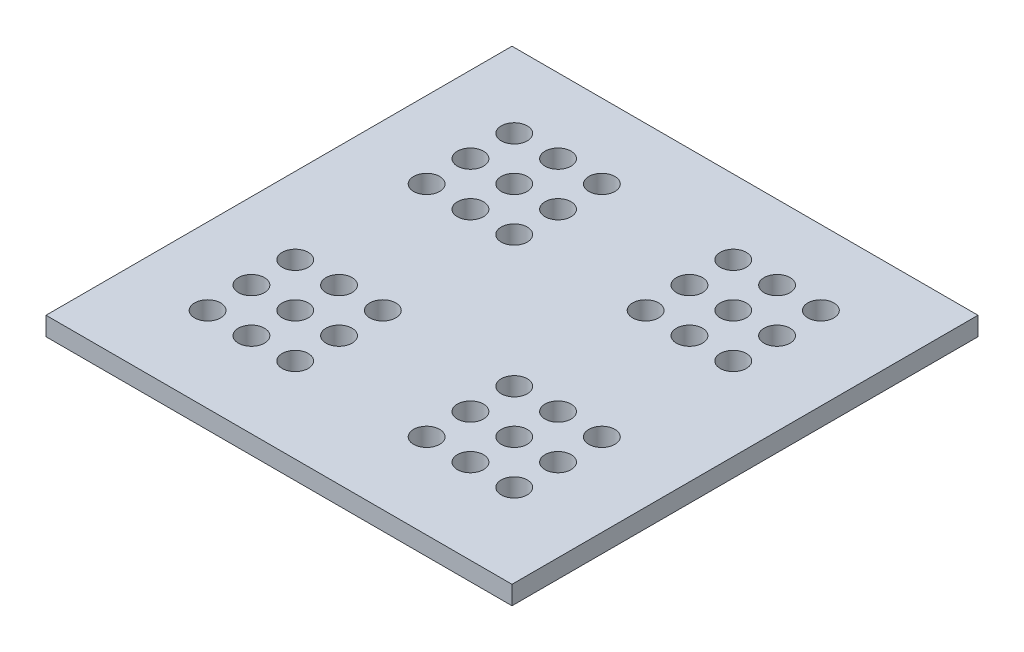
from build123d import *

# Parameters (mm, degrees)
SKETCH1_W           = 25
SKETCH1_H           = 25
SKETCH1_R           = 0.7
BOSS_EXTRUDE2_DEPTH = 1


with BuildPart() as part:
    # Sketch1 → Boss-Extrude2 (new body)
    with BuildSketch(Plane(origin=(0, 0, 0), x_dir=(1, 0, 0), z_dir=(0, 1, 0))):
        Rectangle(SKETCH1_W, SKETCH1_H)
        with Locations((-8.39, 8.51)):
            Circle(SKETCH1_R, mode=Mode.SUBTRACT)
        with Locations((-6.04, 8.51)):
            Circle(SKETCH1_R, mode=Mode.SUBTRACT)
        with Locations((-3.69, 8.51)):
            Circle(SKETCH1_R, mode=Mode.SUBTRACT)
        with Locations((3.36, 8.51)):
            Circle(SKETCH1_R, mode=Mode.SUBTRACT)
        with Locations((5.71, 8.51)):
            Circle(SKETCH1_R, mode=Mode.SUBTRACT)
        with Locations((8.06, 8.51)):
            Circle(SKETCH1_R, mode=Mode.SUBTRACT)
        with Locations((-6.04, 6.16)):
            Circle(SKETCH1_R, mode=Mode.SUBTRACT)
        with Locations((-3.69, 6.16)):
            Circle(SKETCH1_R, mode=Mode.SUBTRACT)
        with Locations((3.36, 6.16)):
            Circle(SKETCH1_R, mode=Mode.SUBTRACT)
        with Locations((5.71, 6.16)):
            Circle(SKETCH1_R, mode=Mode.SUBTRACT)
        with Locations((8.06, 6.16)):
            Circle(SKETCH1_R, mode=Mode.SUBTRACT)
        with Locations((-6.04, 3.81)):
            Circle(SKETCH1_R, mode=Mode.SUBTRACT)
        with Locations((-3.69, 3.81)):
            Circle(SKETCH1_R, mode=Mode.SUBTRACT)
        with Locations((3.36, 3.81)):
            Circle(SKETCH1_R, mode=Mode.SUBTRACT)
        with Locations((5.71, 3.81)):
            Circle(SKETCH1_R, mode=Mode.SUBTRACT)
        with Locations((8.06, 3.81)):
            Circle(SKETCH1_R, mode=Mode.SUBTRACT)
        with Locations((-8.39, 6.16)):
            Circle(SKETCH1_R, mode=Mode.SUBTRACT)
        with Locations((-8.39, 3.81)):
            Circle(SKETCH1_R, mode=Mode.SUBTRACT)
        with Locations((-6.04, -3.24)):
            Circle(SKETCH1_R, mode=Mode.SUBTRACT)
        with Locations((-3.69, -3.24)):
            Circle(SKETCH1_R, mode=Mode.SUBTRACT)
        with Locations((3.36, -3.24)):
            Circle(SKETCH1_R, mode=Mode.SUBTRACT)
        with Locations((5.71, -3.24)):
            Circle(SKETCH1_R, mode=Mode.SUBTRACT)
        with Locations((8.06, -3.24)):
            Circle(SKETCH1_R, mode=Mode.SUBTRACT)
        with Locations((-6.04, -5.59)):
            Circle(SKETCH1_R, mode=Mode.SUBTRACT)
        with Locations((-3.69, -5.59)):
            Circle(SKETCH1_R, mode=Mode.SUBTRACT)
        with Locations((3.36, -5.59)):
            Circle(SKETCH1_R, mode=Mode.SUBTRACT)
        with Locations((5.71, -5.59)):
            Circle(SKETCH1_R, mode=Mode.SUBTRACT)
        with Locations((8.06, -5.59)):
            Circle(SKETCH1_R, mode=Mode.SUBTRACT)
        with Locations((-6.04, -7.94)):
            Circle(SKETCH1_R, mode=Mode.SUBTRACT)
        with Locations((-3.69, -7.94)):
            Circle(SKETCH1_R, mode=Mode.SUBTRACT)
        with Locations((3.36, -7.94)):
            Circle(SKETCH1_R, mode=Mode.SUBTRACT)
        with Locations((5.71, -7.94)):
            Circle(SKETCH1_R, mode=Mode.SUBTRACT)
        with Locations((8.06, -7.94)):
            Circle(SKETCH1_R, mode=Mode.SUBTRACT)
        with Locations((-8.39, -3.24)):
            Circle(SKETCH1_R, mode=Mode.SUBTRACT)
        with Locations((-8.39, -5.59)):
            Circle(SKETCH1_R, mode=Mode.SUBTRACT)
        with Locations((-8.39, -7.94)):
            Circle(SKETCH1_R, mode=Mode.SUBTRACT)
    extrude(amount=BOSS_EXTRUDE2_DEPTH)


solid = part.part
